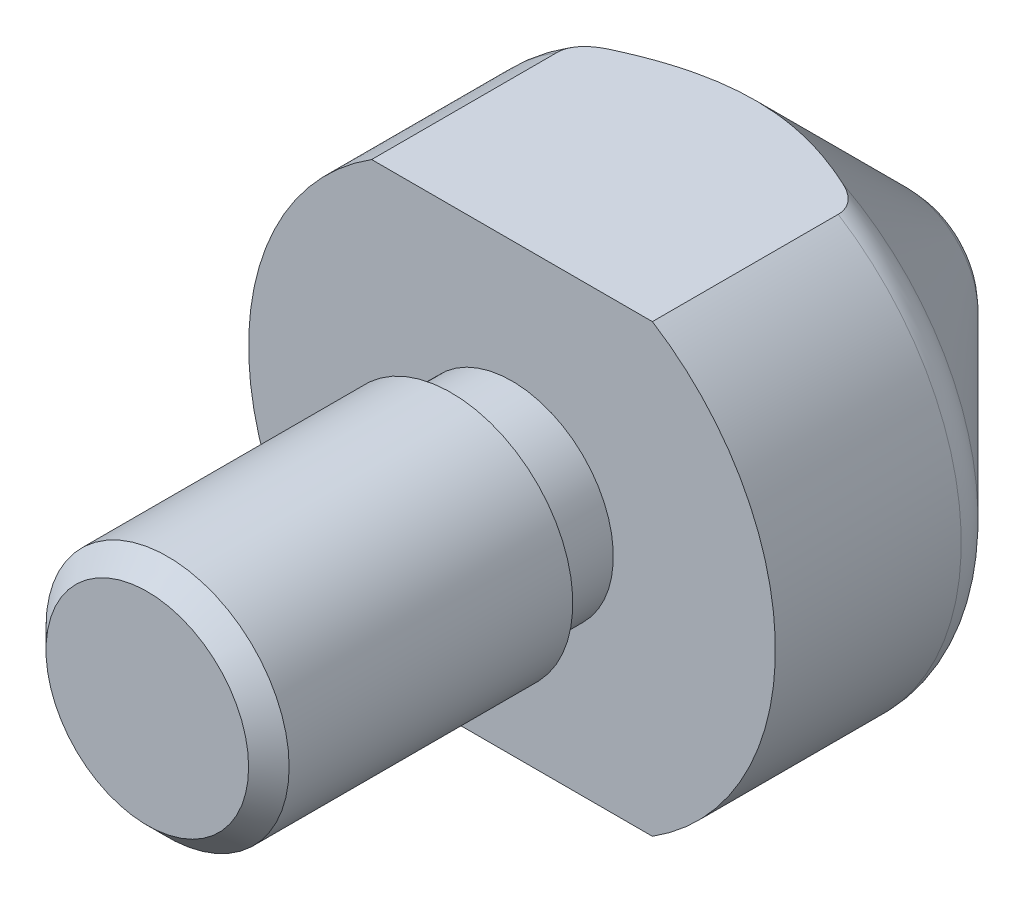
from build123d import *

# Parameters (mm, degrees)
SKETCH2_W               = 46
SKETCH2_H               = 42
SKETCH2_W_2             = 26
SKETCH2_H_2             = 22
CUT_EXTRUDE_THIN1_DEPTH = 21.928932188
CHAMFER1_SIZE           = 1


with BuildPart() as part:
    # Sketch1 → Revolve1 (revolve)
    with BuildSketch(Plane(origin=(0, 0, 0), x_dir=(0, 0, -1), z_dir=(1, 0, 0))):
        with BuildLine():
            Line((1009, 0), (1009, 6))
            Line((1009, 6), (1024, 6))
            Line((1024, 6), (1024, 5))
            Line((1024, 5), (1027, 5))
            Line((1027, 5), (1027, 13))
            Line((1027, 13), (1036.171572875, 13))
            ThreePointArc((1036.171572875, 13), (1036.93693974, 12.847759065), (1037.585786438, 12.414213562))
            Line((1037.585786438, 12.414213562), (1046.464466094, 3.535533906))
            ThreePointArc((1046.464466094, 3.535533906), (1047.548329851, 1.913417162), (1047.928932188, 0))
            Line((1047.928932188, 0), (1009, 0))
        make_face()
    revolve(axis=Axis((0, 0, -1178.108206327), (0, 0, 1)))

    # Sketch2 → Cut-Extrude-Thin1 (cut, through all)
    with BuildSketch(Plane.XY.offset(-1027)):
        Rectangle(SKETCH2_W, SKETCH2_H)
        Rectangle(SKETCH2_W_2, SKETCH2_H_2, mode=Mode.SUBTRACT)
    extrude(amount=-CUT_EXTRUDE_THIN1_DEPTH, mode=Mode.SUBTRACT)

    # Chamfer1
    chamfer1_edges = [part.edges().sort_by_distance(p)[0] for p in [
        (0, -6, -1009),
    ]]
    chamfer(chamfer1_edges, length=CHAMFER1_SIZE)


solid = part.part
